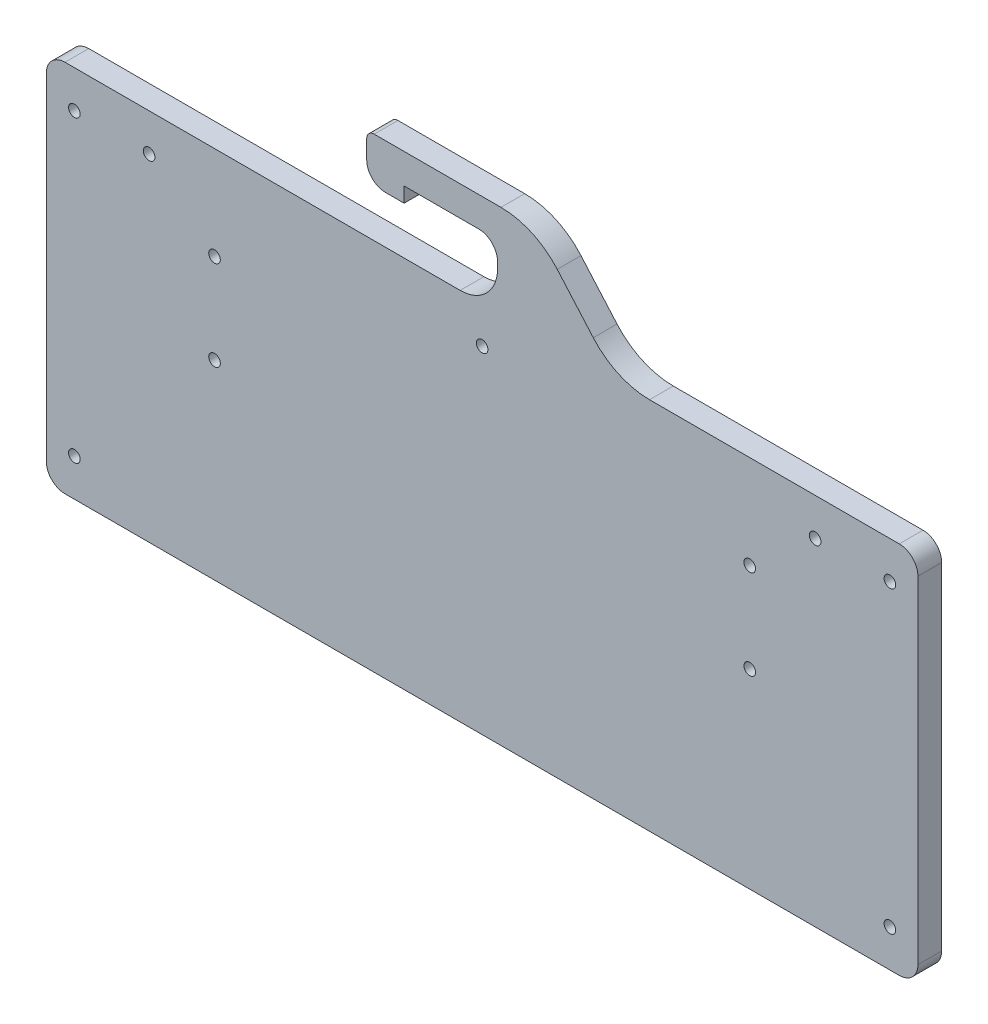
from build123d import *

# Parameters (mm, degrees)
SKETCH1_W           = 233.2
SKETCH1_H           = 100
SKETCH1_R           = 1.55
BOSS_EXTRUDE1_DEPTH = 6.35
FILLET1_R           = 5
SKETCH2_R           = 1.55
CUT_EXTRUDE1_DEPTH  = 6.35
SKETCH3_W           = 10
SKETCH3_H           = 12.7
BOSS_EXTRUDE2_DEPTH = 6.35
FILLET2_R           = 5
FILLET3_R           = 10
FILLET4_R           = 2
FILLET5_R           = 20
FILLET6_R           = 5


with BuildPart() as part:
    # Sketch1 → Boss-Extrude1 (new body)
    with BuildSketch(Plane.XY):
        with Locations((116.6, -50)):
            Rectangle(SKETCH1_W, SKETCH1_H)
        with Locations((7.5, -10)):
            Circle(SKETCH1_R, mode=Mode.SUBTRACT)
        with Locations((225.7, -10)):
            Circle(SKETCH1_R, mode=Mode.SUBTRACT)
        with Locations((7.5, -90)):
            Circle(SKETCH1_R, mode=Mode.SUBTRACT)
        with Locations((225.7, -90)):
            Circle(SKETCH1_R, mode=Mode.SUBTRACT)
        with Locations((27.5, -10)):
            Circle(SKETCH1_R, mode=Mode.SUBTRACT)
        with Locations((205.7, -10)):
            Circle(SKETCH1_R, mode=Mode.SUBTRACT)
        with Locations((116.6, -10)):
            Circle(SKETCH1_R, mode=Mode.SUBTRACT)
    extrude(amount=BOSS_EXTRUDE1_DEPTH)

    # Fillet1
    fillet1_edges = [part.edges().sort_by_distance(p)[0] for p in [
        (233.2, -100, 3.175),
        (0, -100, 3.175),
        (0, 0, 3.175),
        (233.2, 0, 3.175),
    ]]
    fillet(fillet1_edges, radius=FILLET1_R)

    # Sketch2 → Cut-Extrude1 (cut)
    with BuildSketch(Plane.XY.offset(6.35)):
        with Locations((45, -25)):
            Circle(SKETCH2_R)
        with Locations((45, -49)):
            Circle(SKETCH2_R)
        with Locations((188.2, -49)):
            Circle(SKETCH2_R)
        with Locations((188.2, -25)):
            Circle(SKETCH2_R)
    extrude(amount=-CUT_EXTRUDE1_DEPTH, mode=Mode.SUBTRACT)

    # Sketch3 → Boss-Extrude2 (add)
    with BuildSketch(Plane.XY.offset(6.35)):
        with Locations((125.723568259, 6.35)):
            Rectangle(SKETCH3_W, SKETCH3_H)
        Polygon((120.723568259, 16.7), (120.723568259, 12.7), (130.723568259, 12.7), (130.723568259, 24.7), (85.723568259, 24.7), (85.723568259, 12.7), (95.723568259, 12.7), (95.723568259, 16.7), align=None)
        Polygon((130.723568259, 12.7), (130.723568259, 0), (152.313568259, 0), (130.723568259, 24.7), align=None)
    extrude(amount=-BOSS_EXTRUDE2_DEPTH)

    # Fillet2
    fillet2_edges = [part.edges().sort_by_distance(p)[0] for p in [
        (85.723568259, 12.7, 3.175),
    ]]
    fillet(fillet2_edges, radius=FILLET2_R)

    # Fillet3
    fillet3_edges = [part.edges().sort_by_distance(p)[0] for p in [
        (120.723568259, 0, 3.175),
    ]]
    fillet(fillet3_edges, radius=FILLET3_R)

    # Fillet4
    fillet4_edges = [part.edges().sort_by_distance(p)[0] for p in [
        (85.723568259, 24.7, 3.175),
    ]]
    fillet(fillet4_edges, radius=FILLET4_R)

    # Fillet5
    fillet5_edges = [part.edges().sort_by_distance(p)[0] for p in [
        (130.723568259, 24.7, 3.175),
        (152.313568259, 0, 3.175),
    ]]
    fillet(fillet5_edges, radius=FILLET5_R)

    # Fillet6
    fillet6_edges = [part.edges().sort_by_distance(p)[0] for p in [
        (120.723568259, 16.7, 3.175),
    ]]
    fillet(fillet6_edges, radius=FILLET6_R)


solid = part.part
